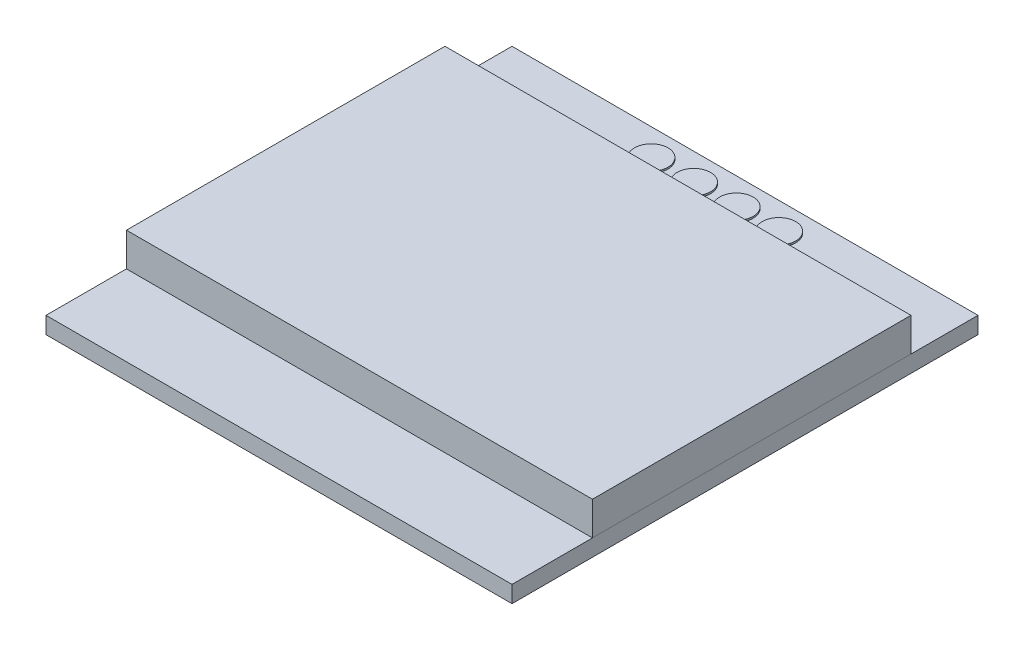
from build123d import *

# Parameters (mm, degrees)
SKETCH1_W             = 27.8
SKETCH1_H             = 27.8
BOSS_EXTRUDE1_DEPTH   = 1
SKETCH2_W             = 27.8
SKETCH2_H             = 19
BOSS_EXTRUDE2_DEPTH   = 2
SKETCH3_R             = 1
BOSS_EXTRUDE3_DEPTH   = 0.1
BOSS_EXTRUDE3_2_DEPTH = 0.1
BOSS_EXTRUDE3_3_DEPTH = 0.1
BOSS_EXTRUDE3_4_DEPTH = 0.1


with BuildPart() as part:
    # Sketch1 → Boss-Extrude1 (new body)
    with BuildSketch(Plane(origin=(0, 0, 0), x_dir=(1, 0, 0), z_dir=(0, 1, 0))):
        with Locations((13.9, 13.9)):
            Rectangle(SKETCH1_W, SKETCH1_H)
    extrude(amount=BOSS_EXTRUDE1_DEPTH)


with BuildPart() as body_2:
    # Sketch2 → Boss-Extrude2 (new body)
    with BuildSketch(Plane(origin=(0, 1, 0), x_dir=(1, 0, 0), z_dir=(0, 1, 0))):
        with Locations((13.9, 14.3)):
            Rectangle(SKETCH2_W, SKETCH2_H)
    extrude(amount=BOSS_EXTRUDE2_DEPTH)


with BuildPart() as body_3:
    # Sketch3 → Boss-Extrude3 (new body)
    with BuildSketch(Plane(origin=(0, 1, 0), x_dir=(1, 0, 0), z_dir=(0, 1, 0))):
        with Locations((10, 26.10685226)):
            Circle(SKETCH3_R)
    extrude(amount=BOSS_EXTRUDE3_DEPTH)


with BuildPart() as body_4:
    # Sketch3 → Boss-Extrude3 2 (new body)
    with BuildSketch(Plane(origin=(0, 1, 0), x_dir=(1, 0, 0), z_dir=(0, 1, 0))):
        with Locations((12.54, 26.10685226)):
            Circle(SKETCH3_R)
    extrude(amount=BOSS_EXTRUDE3_2_DEPTH)


with BuildPart() as body_5:
    # Sketch3 → Boss-Extrude3 3 (new body)
    with BuildSketch(Plane(origin=(0, 1, 0), x_dir=(1, 0, 0), z_dir=(0, 1, 0))):
        with Locations((15.08, 26.10685226)):
            Circle(SKETCH3_R)
    extrude(amount=BOSS_EXTRUDE3_3_DEPTH)


with BuildPart() as body_6:
    # Sketch3 → Boss-Extrude3 4 (new body)
    with BuildSketch(Plane(origin=(0, 1, 0), x_dir=(1, 0, 0), z_dir=(0, 1, 0))):
        with Locations((17.62, 26.10685226)):
            Circle(SKETCH3_R)
    extrude(amount=BOSS_EXTRUDE3_4_DEPTH)


solid = Compound([part.part, body_2.part, body_3.part, body_4.part, body_5.part, body_6.part])
